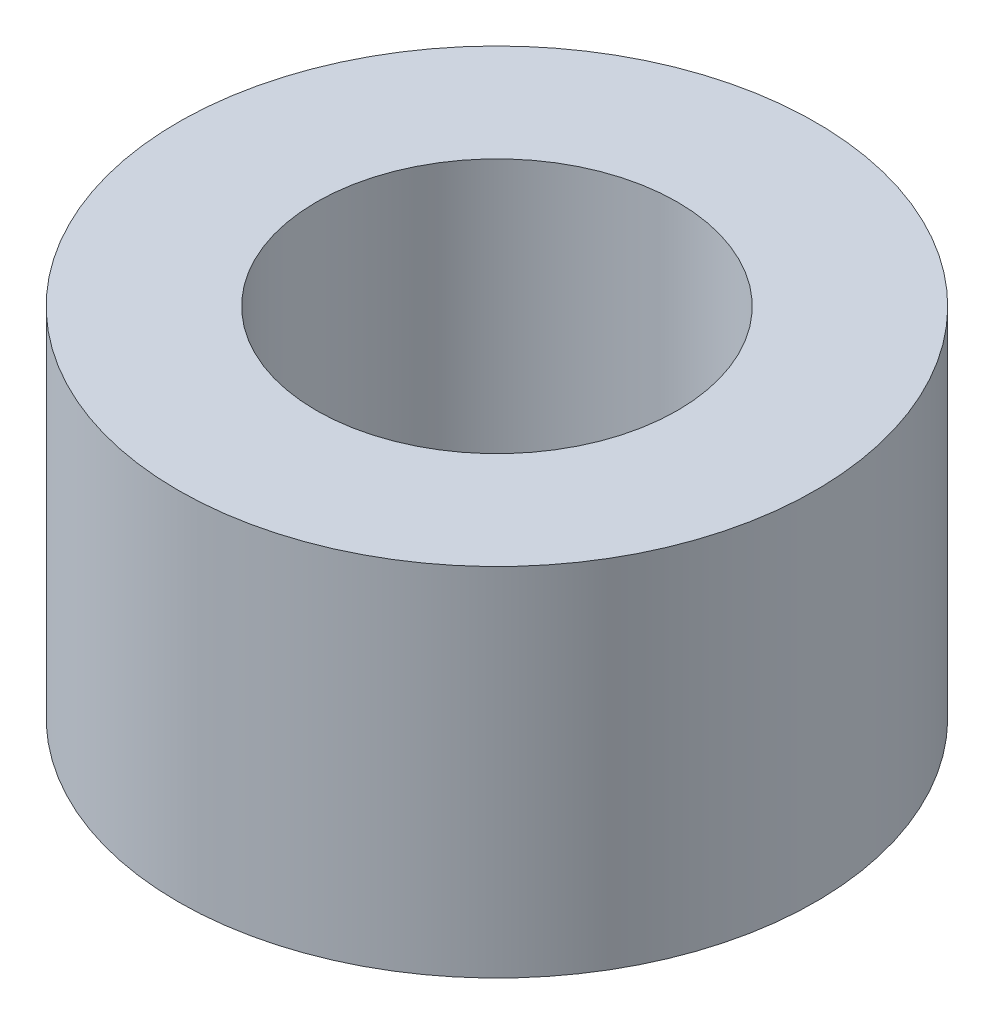
from build123d import *

# Parameters (mm, degrees)
SKETCH1_R           = 5.679302039
SKETCH1_R_2         = 3.21677587
BOSS_EXTRUDE1_DEPTH = 6.35


with BuildPart() as part:
    # Sketch1 → Boss-Extrude1 (new body)
    with BuildSketch(Plane(origin=(0, 0, 0), x_dir=(1, 0, 0), z_dir=(0, 1, 0))):
        Circle(SKETCH1_R)
        Circle(SKETCH1_R_2, mode=Mode.SUBTRACT)
    extrude(amount=BOSS_EXTRUDE1_DEPTH)


solid = part.part
